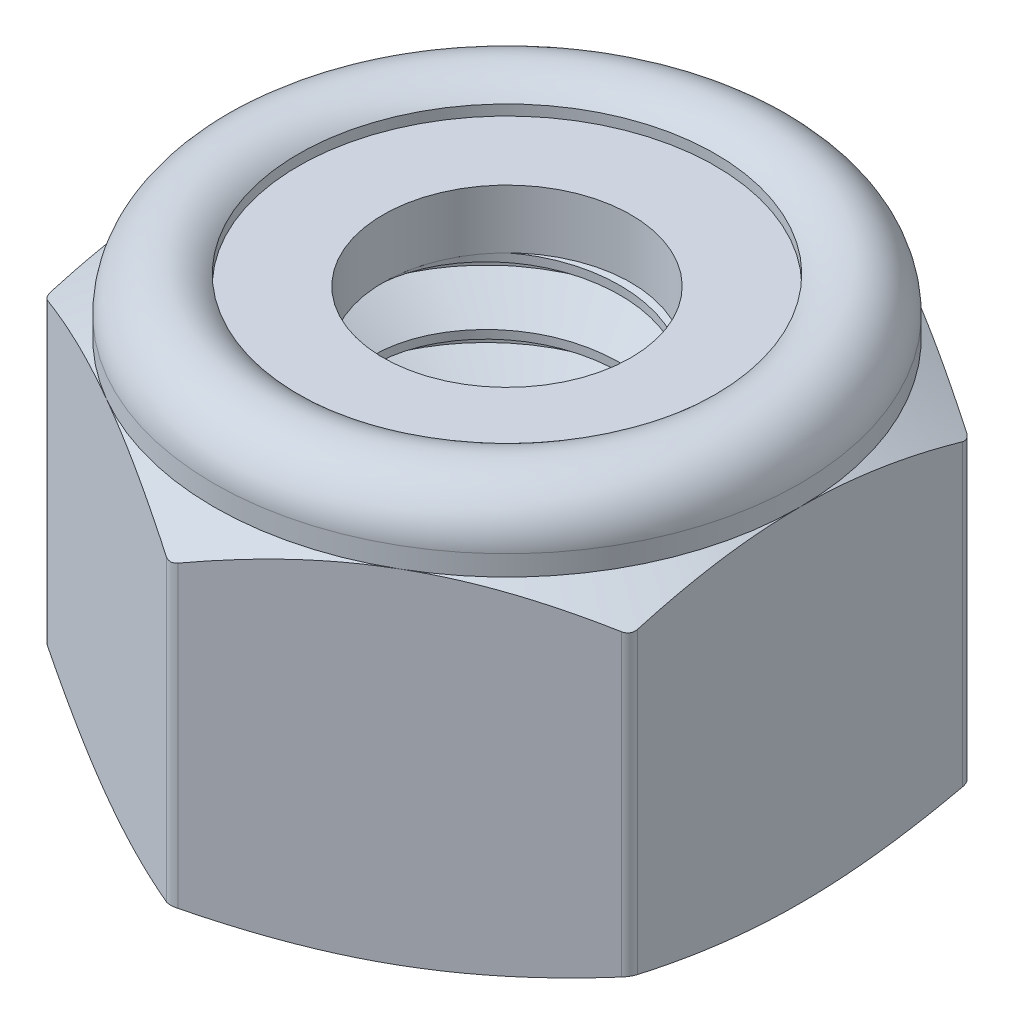
from build123d import *

# Parameters (mm, degrees)
SKETCH2_R                = 2.350110803
BOSS_EXTRUDE1_DEPTH      = 3.96875
BOSS_EXTRUDE1_DEPTH_BACK = 3.96875
FILLET1_R                = 0.22225
SKETCH4_W                = 1.603069598
SKETCH4_H                = 1.11401924
SKETCH6_W                = 3.175
SKETCH6_H                = 6.614583333
CUT_SWEEP1_PITCH         = 1.27
CUT_SWEEP1_HEIGHT        = 7.9375
CUT_SWEEP1_RADIUS        = 3.175
CUT_SWEEP1_START_ANGLE   = 90
SKETCH10_R               = 2.985110803
BOSS_EXTRUDE2_DEPTH      = 6.35


with BuildPart() as part:
    # Sketch2 → Boss-Extrude1 (new, two sides)
    with BuildSketch(Plane(origin=(0, 0, 0), x_dir=(1, 0, 0), z_dir=(0, 1, 0))) as boss_extrude1_sk:
        Polygon((0, 6.415804866), (-5.55625, 3.207902433), (-5.55625, -3.207902433), (0, -6.415804866), (5.55625, -3.207902433), (5.55625, 3.207902433), align=None)
        with Locations(Location((0, 0, 0), (0, 0, 270))):
            Circle(SKETCH2_R, mode=Mode.SUBTRACT)
    extrude(amount=BOSS_EXTRUDE1_DEPTH)
    extrude(boss_extrude1_sk.sketch, amount=-BOSS_EXTRUDE1_DEPTH_BACK)

    # Fillet1
    fillet1_edges = [part.edges().sort_by_distance(p)[0] for p in [
        (5.55625, 0, -3.207902433),
        (5.55625, 0, 3.207902433),
        (0, 0, 6.415804866),
        (-5.55625, 0, 3.207902433),
        (-5.55625, 0, -3.207902433),
        (0, 0, -6.415804866),
    ]]
    fillet(fillet1_edges, radius=FILLET1_R)

    # Sketch3 → Cut-Revolve2 (revolve, cut)
    with BuildSketch(Plane(origin=(0, 0, 0), x_dir=(0, 0, -1), z_dir=(1, 0, 0)), mode=Mode.PRIVATE) as cut_revolve2_sk:
        with BuildLine():
            Line((6.415804866, 2.645833333), (6.415804866, 4.96875))
            Line((6.415804866, 4.96875), (2.350110803, 4.96875))
            Line((2.350110803, 4.96875), (2.350110803, 2.38125))
            Line((2.350110803, 2.38125), (3.953180401, 2.38125))
            Line((3.953180401, 2.38125), (3.953180401, 3.69370674))
            ThreePointArc((3.953180401, 3.69370674), (4.976554908, 3.897268586), (5.55625, 3.029693571))
            Line((5.55625, 3.029693571), (5.55625, 2.645833333))
            Line((5.55625, 2.645833333), (6.415804866, 2.14137944))
            Line((6.415804866, 2.14137944), (6.415804866, 2.645833333))
        make_face()
        Polygon((5.334, -3.96875), (6.415804866, -3.464296106), (6.415804866, -3.96875), align=None)
        Polygon((2.350110803, -3.96875), (2.350110803, -3.33375), (2.985110803, -3.96875), align=None)
    revolve(cut_revolve2_sk.sketch.rotate(Axis((0, -3.96875, 0), (0, 1, 0)), 270), axis=Axis((0, -3.96875, 0), (0, 1, 0)), mode=Mode.SUBTRACT)

    # Sketch10 → Boss-Extrude2 (add)
    with BuildSketch(Plane.XZ.offset(3.96875)):
        Circle(SKETCH10_R)
    extrude(amount=-BOSS_EXTRUDE2_DEPTH)


with BuildPart() as body_2:
    # Sketch4 → Revolve1 (revolve)
    with BuildSketch(Plane(origin=(0, 0, 0), x_dir=(0, 0, -1), z_dir=(1, 0, 0)), mode=Mode.PRIVATE) as revolve1_sk:
        with Locations((-3.151645602, 2.93825962)):
            Rectangle(SKETCH4_W, SKETCH4_H)
    revolve(revolve1_sk.sketch.rotate(Axis((0, -3.96875, 0), (0, 1, 0)), 90), axis=Axis((0, -3.96875, 0), (0, 1, 0)))


with BuildPart() as body_3:
    # Sketch6 → Revolve2 (revolve)
    with BuildSketch(Plane.XY, mode=Mode.PRIVATE) as revolve2_sk:
        with Locations((1.5875, -0.661458334)):
            Rectangle(SKETCH6_W, SKETCH6_H)
    revolve(revolve2_sk.sketch.rotate(Axis((0, -3.96875, 0), (0, 1, 0)), 90), axis=Axis((0, -3.96875, 0), (0, 1, 0)))

    # Cut-Sweep1: sweep along a helix
    with BuildLine() as cut_sweep1_path:
        add(Helix(CUT_SWEEP1_PITCH, CUT_SWEEP1_HEIGHT, CUT_SWEEP1_RADIUS, center=(0, -3.96875, 0), direction=(0, 1, 0), mode=Mode.PRIVATE).rotate(Axis((0, -3.96875, 0), (0, 1, 0)), CUT_SWEEP1_START_ANGLE))
    # Sketch8 → Cut-Sweep1 (sweep, cut)
    with BuildSketch(Plane.XY):
        Polygon((2.350110803, -4.445), (2.350110803, -4.60375), (3.243740766, -5.1196875), (3.312481533, -3.889375), align=None)
    sweep(path=cut_sweep1_path.line, is_frenet=True, mode=Mode.SUBTRACT)

    # Sketch9 → Revolve3 (revolve)
    with BuildSketch(Plane.XY, mode=Mode.PRIVATE) as revolve3_sk:
        Polygon((0, -0.79375), (0, -3.96875), (3.175, -3.96875), (3.81, -3.96875), (0, -0.15875), align=None)
    revolve(revolve3_sk.sketch.rotate(Axis((0, -0.79375, 0), (0, -1, 0)), 180), axis=Axis((0, -0.79375, 0), (0, -1, 0)))


with BuildPart() as part_1:
    add(part.part)

    # Combine1: cut body 3
    add(body_3.part, mode=Mode.SUBTRACT)


solid = Compound([body_2.part, part_1.part])
